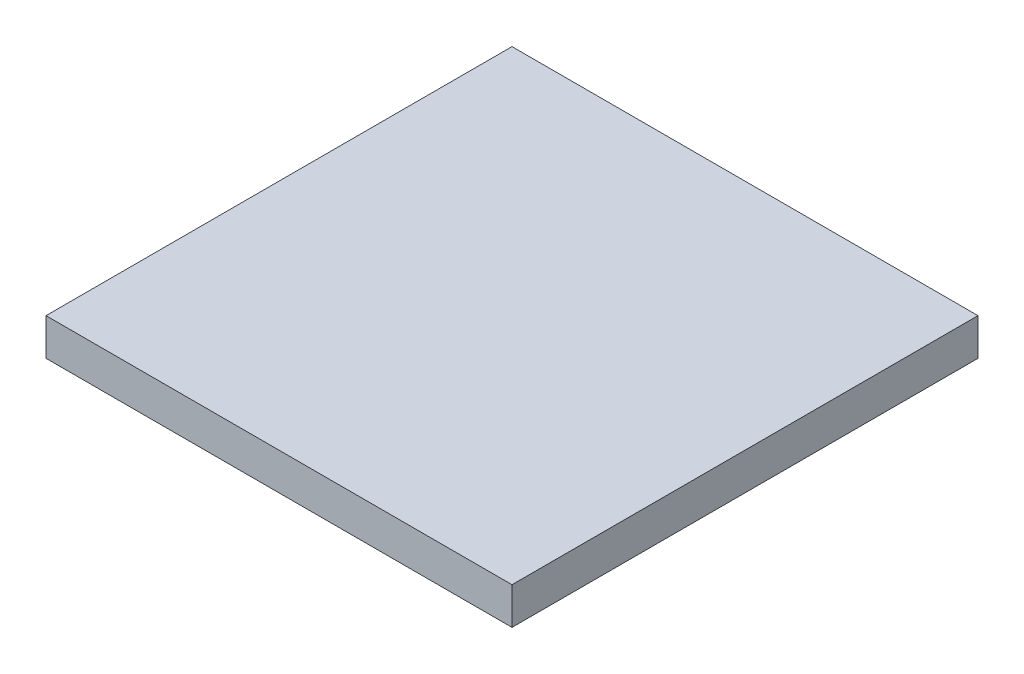
from build123d import *

# Parameters (mm, degrees)
SKETCH1_W           = 80.01
SKETCH1_H           = 80.01
BOSS_EXTRUDE1_DEPTH = 6.35


with BuildPart() as part:
    # Sketch1 → Boss-Extrude1 (new body)
    with BuildSketch(Plane(origin=(0, 0, 0), x_dir=(1, 0, 0), z_dir=(0, 1, 0))):
        with Locations((40.005, -40.005)):
            Rectangle(SKETCH1_W, SKETCH1_H)
    extrude(amount=BOSS_EXTRUDE1_DEPTH)


solid = part.part
